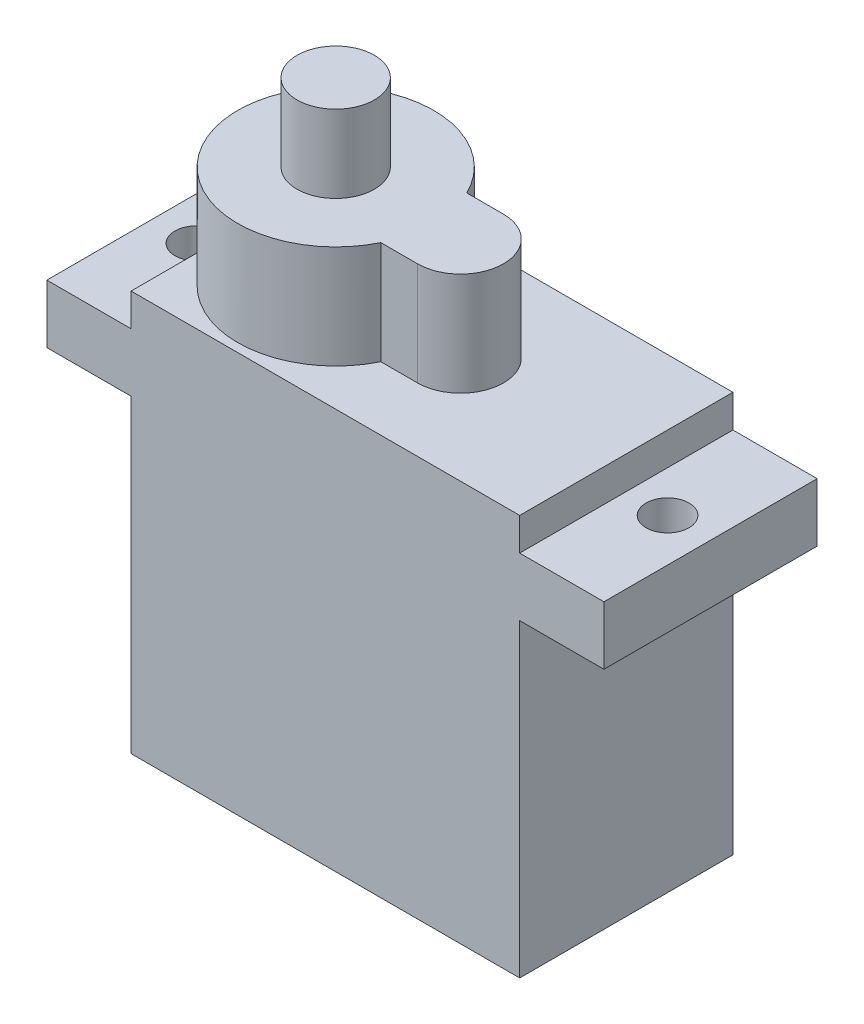
from build123d import *

# Parameters (mm, degrees)
SKETCH_1_W      = 22.6
SKETCH_1_H      = 12.4
EXTRUDE_1_DEPTH = 18
SKETCH_2_W      = 32.4
SKETCH_2_H      = 12.4
SKETCH_2_R      = 1.25
EXTRUDE_2_DEPTH = 3.4
SKETCH_3_W      = 22.6
SKETCH_3_H      = 12.4
EXTRUDE_3_DEPTH = 1.9
EXTRUDE_4_DEPTH = 6
SKETCH_5_R      = 2.25
EXTRUDE_5_DEPTH = 4.5


with BuildPart() as part:
    # 草图1 → 凸台-拉伸1 (new body)
    with BuildSketch(Plane(origin=(0, 0, 0), x_dir=(1, 0, 0), z_dir=(0, 1, 0))):
        Rectangle(SKETCH_1_W, SKETCH_1_H)
    extrude(amount=EXTRUDE_1_DEPTH)

    # 草图2 → 凸台-拉伸2 (add)
    with BuildSketch(Plane(origin=(0, 18, 0), x_dir=(1, 0, 0), z_dir=(0, 1, 0))):
        Rectangle(SKETCH_2_W, SKETCH_2_H)
        with Locations((-13.7, 0)):
            Circle(SKETCH_2_R, mode=Mode.SUBTRACT)
        with Locations((13.7, 0)):
            Circle(SKETCH_2_R, mode=Mode.SUBTRACT)
    extrude(amount=EXTRUDE_2_DEPTH)

    # 草图3 → 凸台-拉伸3 (add)
    with BuildSketch(Plane(origin=(0, 21.4, 0), x_dir=(1, 0, 0), z_dir=(0, 1, 0))):
        Rectangle(SKETCH_3_W, SKETCH_3_H)
    extrude(amount=EXTRUDE_3_DEPTH)

    # 草图4 → 凸台-拉伸4 (add)
    with BuildSketch(Plane(origin=(0, 23.3, 0), x_dir=(1, 0, 0), z_dir=(0, 1, 0))):
        with BuildLine():
            Line((1.659485126, 2.5), (-0.47750061, 2.5))
            ThreePointArc((-0.47750061, 2.5), (-11.3, 0), (-0.47750061, -2.5))
            Line((-0.47750061, -2.5), (1.659485126, -2.5))
            ThreePointArc((1.659485126, -2.5), (4.159485126, 0), (1.659485126, 2.5))
        make_face()
    extrude(amount=EXTRUDE_4_DEPTH)

    # 草图5 → 凸台-拉伸5 (add)
    with BuildSketch(Plane(origin=(0, 29.3, 0), x_dir=(1, 0, 0), z_dir=(0, 1, 0))):
        with Locations((-5.6, 0)):
            Circle(SKETCH_5_R)
    extrude(amount=EXTRUDE_5_DEPTH)


solid = part.part
